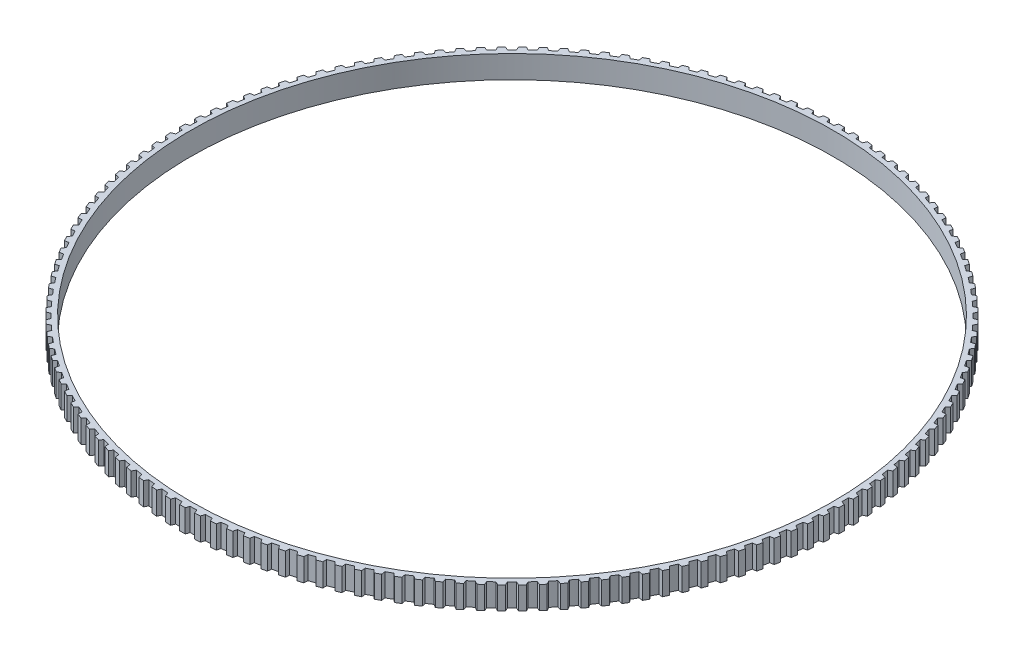
from build123d import *

# Parameters (mm, degrees)
SKETCH1_R      = 44.8691
EXTRUDE1_DEPTH = 3.175


with BuildPart() as part:
    # Sketch1 → Extrude1 (new body)
    with BuildSketch(Plane(origin=(0, 0, 0), x_dir=(1, 0, 0), z_dir=(0, 1, 0))):
        with BuildLine():
            Line((-0.381, 46.010522551), (-0.566606736, 45.500572234))
            ThreePointArc((-0.566606736, 45.500572234), (-1.021023922, 45.492643658), (-1.475339253, 45.4801769))
            Line((-1.475339253, 45.4801769), (-1.68363793, 45.981286517))
            ThreePointArc((-1.68363793, 45.981286517), (-2.064325061, 45.965768877), (-2.444870647, 45.947099516))
            Line((-2.444870647, 45.947099516), (-2.607411655, 45.42933547))
            ThreePointArc((-2.607411655, 45.42933547), (-3.061015558, 45.401027528), (-3.514314106, 45.368190543))
            Line((-3.514314106, 45.368190543), (-3.744885238, 45.859450291))
            ThreePointArc((-3.744885238, 45.859450291), (-4.124492845, 45.826868813), (-4.50381765, 45.791145137))
            Line((-4.50381765, 45.791145137), (-4.642965594, 45.266610071))
            ThreePointArc((-4.642965594, 45.266610071), (-5.094842717, 45.21797977), (-5.546211597, 45.164838688))
            Line((-5.546211597, 45.164838688), (-5.798590845, 45.645259235))
            ThreePointArc((-5.798590845, 45.645259235), (-6.17635445, 45.595679533), (-6.553694563, 45.542973486))
            Line((-6.553694563, 45.542973486), (-6.669169218, 45.012723743))
            ThreePointArc((-6.669169218, 45.012723743), (-7.118409541, 44.943869019), (-7.566939757, 44.870530859))
            Line((-7.566939757, 44.870530859), (-7.840618862, 45.339144702))
            ThreePointArc((-7.840618862, 45.339144702), (-8.215777699, 45.272666624), (-8.590373208, 45.203084348))
            Line((-8.590373208, 45.203084348), (-8.681942023, 44.66818778))
            ThreePointArc((-8.681942023, 44.66818778), (-9.127640835, 44.579247297), (-9.572429107, 44.485859751))
            Line((-9.572429107, 44.485859751), (-9.866856915, 44.941723165))
            ThreePointArc((-9.866856915, 44.941723165), (-10.238655465, 44.858480588), (-10.609751984, 44.772162213))
            Line((-10.609751984, 44.772162213), (-10.677230552, 44.233696031))
            ThreePointArc((-10.677230552, 44.233696031), (-11.118490275, 44.124848904), (-11.558640858, 44.011600043))
            Line((-11.558640858, 44.011600043), (-11.873224432, 44.453794978))
            ThreePointArc((-11.873224432, 44.453794978), (-12.240913942, 44.353955543), (-12.607764132, 44.251074902))
            Line((-12.607764132, 44.251074902), (-12.651016559, 43.710123505))
            ThreePointArc((-12.651016559, 43.710123505), (-13.086948555, 43.581588938), (-13.521575045, 43.448706829))
            Line((-13.521575045, 43.448706829), (-13.855680856, 43.876342765))
            ThreePointArc((-13.855680856, 43.876342765), (-14.218520847, 43.760107533), (-14.580385921, 43.640871815))
            Line((-14.580385921, 43.640871815), (-14.599325103, 43.098524608))
            ThreePointArc((-14.599325103, 43.098524608), (-15.029051463, 42.950561451), (-15.45727858, 42.798313702))
            Line((-15.45727858, 42.798313702), (-15.810233782, 43.210529437))
            ThreePointArc((-15.810233782, 43.210529437), (-16.167493543, 43.078132491), (-16.523644753, 42.942781821))
            Line((-16.523644753, 42.942781821), (-16.518232549, 42.400131017))
            ThreePointArc((-16.518232549, 42.400131017), (-16.940887861, 42.233037249), (-17.361853212, 42.061730467))
            Line((-17.361853212, 42.061730467), (-17.732947001, 42.457695852))
            ThreePointArc((-17.732947001, 42.457695852), (-18.083907059, 42.309403823), (-18.433627163, 42.158210778))
            Line((-18.433627163, 42.158210778), (-18.403874473, 41.616349206))
            ThreePointArc((-18.403874473, 41.616349206), (-18.818607566, 41.430461331), (-19.231463383, 41.240440504))
            Line((-19.231463383, 41.240440504), (-19.619948424, 41.619358119))
            ThreePointArc((-19.619948424, 41.619358119), (-19.963901993, 41.455469647), (-20.306486702, 41.28873871))
            Line((-20.306486702, 41.28873871), (-20.252453443, 40.748757605))
            ThreePointArc((-20.252453443, 40.748757605), (-20.658429099, 40.544449977), (-21.062343946, 40.336097782))
            Line((-21.062343946, 40.336097782), (-21.467437883, 40.697204537))
            ThreePointArc((-21.467437883, 40.697204537), (-21.803692285, 40.518049671), (-22.138451679, 40.336116616))
            Line((-22.138451679, 40.336116616), (-22.060246667, 39.79910343))
            ThreePointArc((-22.060246667, 39.79910343), (-22.456647306, 39.576787497), (-22.850807751, 39.350523528))
            Line((-22.850807751, 39.350523528), (-23.271694779, 39.693092202))
            ThreePointArc((-23.271694779, 39.693092202), (-23.599572842, 39.499031736), (-23.92583276, 39.302262952))
            Line((-23.92583276, 39.302262952), (-23.82361349, 38.769299157))
            ThreePointArc((-23.82361349, 38.769299157), (-24.209640813, 38.529422634), (-24.59325307, 38.285702556))
            Line((-24.59325307, 38.285702556), (-25.029085579, 38.609043261))
            ThreePointArc((-25.029085579, 38.609043261), (-25.347927, 38.400468008), (-25.665030398, 38.189259761))
            Line((-25.665030398, 38.189259761), (-25.539002726, 37.661418675))
            ThreePointArc((-25.539002726, 37.661418675), (-25.913879326, 37.404464641), (-26.286170851, 37.143779275))
            Line((-26.286170851, 37.143779275), (-26.736071131, 37.447240845))
            ThreePointArc((-26.736071131, 37.447240845), (-27.045233807, 37.224570847), (-27.352542081, 36.999348483))
            Line((-27.352542081, 36.999348483), (-27.202959809, 36.477693108))
            ThreePointArc((-27.202959809, 36.477693108), (-27.565930734, 36.204179035), (-27.926151782, 35.927053365))
            Line((-27.926151782, 35.927053365), (-28.389213794, 36.21002467))
            ThreePointArc((-28.389213794, 36.21002467), (-28.688075112, 35.973708354), (-28.984969384, 35.734925441))
            Line((-28.984969384, 35.734925441), (-28.812133751, 35.220506321))
            ThreePointArc((-28.812133751, 35.220506321), (-29.162468026, 34.93098303), (-29.50989316, 34.63797515))
            Line((-29.50989316, 34.63797515), (-29.985184358, 34.899886324))
            ThreePointArc((-29.985184358, 34.899886324), (-30.273142452, 34.650399601), (-30.559024816, 34.398537014))
            Line((-30.559024816, 34.398537014), (-30.363283891, 33.892390122))
            ThreePointArc((-30.363283891, 33.892390122), (-30.700275989, 33.587440674), (-31.03420554, 33.279140664))
            Line((-31.03420554, 33.279140664), (-31.520768752, 33.519464251))
            ThreePointArc((-31.520768752, 33.519464251), (-31.797243711, 33.257309554), (-32.071538438, 32.992874513))
            Line((-32.071538438, 32.992874513), (-31.853286417, 32.49601916))
            ThreePointArc((-31.853286417, 32.49601916), (-32.176257682, 32.176257682), (-32.49601916, 31.853286417))
            Line((-32.49601916, 31.853286417), (-32.992874513, 32.071538438))
            ThreePointArc((-32.992874513, 32.071538438), (-33.257309554, 31.797243711), (-33.519464251, 31.520768752))
            Line((-33.519464251, 31.520768752), (-33.279140664, 31.03420554))
            ThreePointArc((-33.279140664, 31.03420554), (-33.587440674, 30.700275989), (-33.892390122, 30.363283891))
            Line((-33.892390122, 30.363283891), (-34.398537014, 30.559024816))
            ThreePointArc((-34.398537014, 30.559024816), (-34.650399601, 30.273142452), (-34.899886324, 29.985184358))
            Line((-34.899886324, 29.985184358), (-34.63797515, 29.50989316))
            ThreePointArc((-34.63797515, 29.50989316), (-34.93098303, 29.162468026), (-35.220506321, 28.812133751))
            Line((-35.220506321, 28.812133751), (-35.734925441, 28.984969384))
            ThreePointArc((-35.734925441, 28.984969384), (-35.973708354, 28.688075112), (-36.21002467, 28.389213794))
            Line((-36.21002467, 28.389213794), (-35.927053365, 27.926151782))
            ThreePointArc((-35.927053365, 27.926151782), (-36.204179035, 27.565930734), (-36.477693108, 27.202959809))
            Line((-36.477693108, 27.202959809), (-36.999348483, 27.352542081))
            ThreePointArc((-36.999348483, 27.352542081), (-37.224570847, 27.045233807), (-37.447240845, 26.736071131))
            Line((-37.447240845, 26.736071131), (-37.143779275, 26.286170851))
            ThreePointArc((-37.143779275, 26.286170851), (-37.404464641, 25.913879326), (-37.661418675, 25.539002726))
            Line((-37.661418675, 25.539002726), (-38.189259761, 25.665030398))
            ThreePointArc((-38.189259761, 25.665030398), (-38.400468008, 25.347927), (-38.609043261, 25.029085579))
            Line((-38.609043261, 25.029085579), (-38.285702556, 24.59325307))
            ThreePointArc((-38.285702556, 24.59325307), (-38.529422634, 24.209640813), (-38.769299157, 23.82361349))
            Line((-38.769299157, 23.82361349), (-39.302262952, 23.92583276))
            ThreePointArc((-39.302262952, 23.92583276), (-39.499031736, 23.599572842), (-39.693092202, 23.271694779))
            Line((-39.693092202, 23.271694779), (-39.350523528, 22.850807751))
            ThreePointArc((-39.350523528, 22.850807751), (-39.576787497, 22.456647306), (-39.79910343, 22.060246667))
            Line((-39.79910343, 22.060246667), (-40.336116616, 22.138451679))
            ThreePointArc((-40.336116616, 22.138451679), (-40.518049671, 21.803692285), (-40.697204537, 21.467437883))
            Line((-40.697204537, 21.467437883), (-40.336097782, 21.062343946))
            ThreePointArc((-40.336097782, 21.062343946), (-40.544449977, 20.658429099), (-40.748757605, 20.252453443))
            Line((-40.748757605, 20.252453443), (-41.28873871, 20.306486702))
            ThreePointArc((-41.28873871, 20.306486702), (-41.455469647, 19.963901993), (-41.619358119, 19.619948424))
            Line((-41.619358119, 19.619948424), (-41.240440504, 19.231463383))
            ThreePointArc((-41.240440504, 19.231463383), (-41.430461331, 18.818607566), (-41.616349206, 18.403874473))
            Line((-41.616349206, 18.403874473), (-42.158210778, 18.433627163))
            ThreePointArc((-42.158210778, 18.433627163), (-42.309403823, 18.083907059), (-42.457695852, 17.732947001))
            Line((-42.457695852, 17.732947001), (-42.061730467, 17.361853212))
            ThreePointArc((-42.061730467, 17.361853212), (-42.233037249, 16.940887861), (-42.400131017, 16.518232549))
            Line((-42.400131017, 16.518232549), (-42.942781821, 16.523644753))
            ThreePointArc((-42.942781821, 16.523644753), (-43.078132491, 16.167493543), (-43.210529437, 15.810233782))
            Line((-43.210529437, 15.810233782), (-42.798313702, 15.45727858))
            ThreePointArc((-42.798313702, 15.45727858), (-42.950561451, 15.029051463), (-43.098524608, 14.599325103))
            Line((-43.098524608, 14.599325103), (-43.640871815, 14.580385921))
            ThreePointArc((-43.640871815, 14.580385921), (-43.760107533, 14.218520847), (-43.876342765, 13.855680856))
            Line((-43.876342765, 13.855680856), (-43.448706829, 13.521575045))
            ThreePointArc((-43.448706829, 13.521575045), (-43.581588938, 13.086948555), (-43.710123505, 12.651016559))
            Line((-43.710123505, 12.651016559), (-44.251074902, 12.607764132))
            ThreePointArc((-44.251074902, 12.607764132), (-44.353955543, 12.240913942), (-44.453794978, 11.873224432))
            Line((-44.453794978, 11.873224432), (-44.011600043, 11.558640858))
            ThreePointArc((-44.011600043, 11.558640858), (-44.124848904, 11.118490275), (-44.233696031, 10.677230552))
            Line((-44.233696031, 10.677230552), (-44.772162213, 10.609751984))
            ThreePointArc((-44.772162213, 10.609751984), (-44.858480588, 10.238655465), (-44.941723165, 9.866856915))
            Line((-44.941723165, 9.866856915), (-44.485859751, 9.572429107))
            ThreePointArc((-44.485859751, 9.572429107), (-44.579247297, 9.127640835), (-44.66818778, 8.681942023))
            Line((-44.66818778, 8.681942023), (-45.203084348, 8.590373208))
            ThreePointArc((-45.203084348, 8.590373208), (-45.272666624, 8.215777699), (-45.339144702, 7.840618862))
            Line((-45.339144702, 7.840618862), (-44.870530859, 7.566939757))
            ThreePointArc((-44.870530859, 7.566939757), (-44.943869019, 7.118409541), (-45.012723743, 6.669169218))
            Line((-45.012723743, 6.669169218), (-45.542973486, 6.553694563))
            ThreePointArc((-45.542973486, 6.553694563), (-45.595679533, 6.17635445), (-45.645259235, 5.798590845))
            Line((-45.645259235, 5.798590845), (-45.164838688, 5.546211597))
            ThreePointArc((-45.164838688, 5.546211597), (-45.21797977, 5.094842717), (-45.266610071, 4.642965594))
            Line((-45.266610071, 4.642965594), (-45.791145137, 4.50381765))
            ThreePointArc((-45.791145137, 4.50381765), (-45.826868813, 4.124492845), (-45.859450291, 3.744885238))
            Line((-45.859450291, 3.744885238), (-45.368190543, 3.514314106))
            ThreePointArc((-45.368190543, 3.514314106), (-45.401027528, 3.061015558), (-45.42933547, 2.607411655))
            Line((-45.42933547, 2.607411655), (-45.947099516, 2.444870647))
            ThreePointArc((-45.947099516, 2.444870647), (-45.965768877, 2.064325061), (-45.981286517, 1.68363793))
            Line((-45.981286517, 1.68363793), (-45.4801769, 1.475339253))
            ThreePointArc((-45.4801769, 1.475339253), (-45.492643658, 1.021023922), (-45.500572234, 0.566606736))
            Line((-45.500572234, 0.566606736), (-46.010522551, 0.381))
            ThreePointArc((-46.010522551, 0.381), (-46.0121, 0), (-46.010522551, -0.381))
            Line((-46.010522551, -0.381), (-45.500572234, -0.566606736))
            ThreePointArc((-45.500572234, -0.566606736), (-45.492643658, -1.021023922), (-45.4801769, -1.475339253))
            Line((-45.4801769, -1.475339253), (-45.981286517, -1.68363793))
            ThreePointArc((-45.981286517, -1.68363793), (-45.965768877, -2.064325061), (-45.947099516, -2.444870647))
            Line((-45.947099516, -2.444870647), (-45.42933547, -2.607411655))
            ThreePointArc((-45.42933547, -2.607411655), (-45.401027528, -3.061015558), (-45.368190543, -3.514314106))
            Line((-45.368190543, -3.514314106), (-45.859450291, -3.744885238))
            ThreePointArc((-45.859450291, -3.744885238), (-45.826868813, -4.124492845), (-45.791145137, -4.50381765))
            Line((-45.791145137, -4.50381765), (-45.266610071, -4.642965594))
            ThreePointArc((-45.266610071, -4.642965594), (-45.21797977, -5.094842717), (-45.164838688, -5.546211597))
            Line((-45.164838688, -5.546211597), (-45.645259235, -5.798590845))
            ThreePointArc((-45.645259235, -5.798590845), (-45.595679533, -6.17635445), (-45.542973486, -6.553694563))
            Line((-45.542973486, -6.553694563), (-45.012723743, -6.669169218))
            ThreePointArc((-45.012723743, -6.669169218), (-44.943869019, -7.118409541), (-44.870530859, -7.566939757))
            Line((-44.870530859, -7.566939757), (-45.339144702, -7.840618862))
            ThreePointArc((-45.339144702, -7.840618862), (-45.272666624, -8.215777699), (-45.203084348, -8.590373208))
            Line((-45.203084348, -8.590373208), (-44.66818778, -8.681942023))
            ThreePointArc((-44.66818778, -8.681942023), (-44.579247297, -9.127640835), (-44.485859751, -9.572429107))
            Line((-44.485859751, -9.572429107), (-44.941723165, -9.866856915))
            ThreePointArc((-44.941723165, -9.866856915), (-44.858480588, -10.238655465), (-44.772162213, -10.609751984))
            Line((-44.772162213, -10.609751984), (-44.233696031, -10.677230552))
            ThreePointArc((-44.233696031, -10.677230552), (-44.124848904, -11.118490275), (-44.011600043, -11.558640858))
            Line((-44.011600043, -11.558640858), (-44.453794978, -11.873224432))
            ThreePointArc((-44.453794978, -11.873224432), (-44.353955543, -12.240913942), (-44.251074902, -12.607764132))
            Line((-44.251074902, -12.607764132), (-43.710123505, -12.651016559))
            ThreePointArc((-43.710123505, -12.651016559), (-43.581588938, -13.086948555), (-43.448706829, -13.521575045))
            Line((-43.448706829, -13.521575045), (-43.876342765, -13.855680856))
            ThreePointArc((-43.876342765, -13.855680856), (-43.760107533, -14.218520847), (-43.640871815, -14.580385921))
            Line((-43.640871815, -14.580385921), (-43.098524608, -14.599325103))
            ThreePointArc((-43.098524608, -14.599325103), (-42.950561451, -15.029051463), (-42.798313702, -15.45727858))
            Line((-42.798313702, -15.45727858), (-43.210529437, -15.810233782))
            ThreePointArc((-43.210529437, -15.810233782), (-43.078132491, -16.167493543), (-42.942781821, -16.523644753))
            Line((-42.942781821, -16.523644753), (-42.400131017, -16.518232549))
            ThreePointArc((-42.400131017, -16.518232549), (-42.233037249, -16.940887861), (-42.061730467, -17.361853212))
            Line((-42.061730467, -17.361853212), (-42.457695852, -17.732947001))
            ThreePointArc((-42.457695852, -17.732947001), (-42.309403823, -18.083907059), (-42.158210778, -18.433627163))
            Line((-42.158210778, -18.433627163), (-41.616349206, -18.403874473))
            ThreePointArc((-41.616349206, -18.403874473), (-41.430461331, -18.818607566), (-41.240440504, -19.231463383))
            Line((-41.240440504, -19.231463383), (-41.619358119, -19.619948424))
            ThreePointArc((-41.619358119, -19.619948424), (-41.455469647, -19.963901993), (-41.28873871, -20.306486702))
            Line((-41.28873871, -20.306486702), (-40.748757605, -20.252453443))
            ThreePointArc((-40.748757605, -20.252453443), (-40.544449977, -20.658429099), (-40.336097782, -21.062343946))
            Line((-40.336097782, -21.062343946), (-40.697204537, -21.467437883))
            ThreePointArc((-40.697204537, -21.467437883), (-40.518049671, -21.803692285), (-40.336116616, -22.138451679))
            Line((-40.336116616, -22.138451679), (-39.79910343, -22.060246667))
            ThreePointArc((-39.79910343, -22.060246667), (-39.576787497, -22.456647306), (-39.350523528, -22.850807751))
            Line((-39.350523528, -22.850807751), (-39.693092202, -23.271694779))
            ThreePointArc((-39.693092202, -23.271694779), (-39.499031736, -23.599572842), (-39.302262952, -23.92583276))
            Line((-39.302262952, -23.92583276), (-38.769299157, -23.82361349))
            ThreePointArc((-38.769299157, -23.82361349), (-38.529422634, -24.209640813), (-38.285702556, -24.59325307))
            Line((-38.285702556, -24.59325307), (-38.609043261, -25.029085579))
            ThreePointArc((-38.609043261, -25.029085579), (-38.400468008, -25.347927), (-38.189259761, -25.665030398))
            Line((-38.189259761, -25.665030398), (-37.661418675, -25.539002726))
            ThreePointArc((-37.661418675, -25.539002726), (-37.404464641, -25.913879326), (-37.143779275, -26.286170851))
            Line((-37.143779275, -26.286170851), (-37.447240845, -26.736071131))
            ThreePointArc((-37.447240845, -26.736071131), (-37.224570847, -27.045233807), (-36.999348483, -27.352542081))
            Line((-36.999348483, -27.352542081), (-36.477693108, -27.202959809))
            ThreePointArc((-36.477693108, -27.202959809), (-36.204179035, -27.565930734), (-35.927053365, -27.926151782))
            Line((-35.927053365, -27.926151782), (-36.21002467, -28.389213794))
            ThreePointArc((-36.21002467, -28.389213794), (-35.973708354, -28.688075112), (-35.734925441, -28.984969384))
            Line((-35.734925441, -28.984969384), (-35.220506321, -28.812133751))
            ThreePointArc((-35.220506321, -28.812133751), (-34.93098303, -29.162468026), (-34.63797515, -29.50989316))
            Line((-34.63797515, -29.50989316), (-34.899886324, -29.985184358))
            ThreePointArc((-34.899886324, -29.985184358), (-34.650399601, -30.273142452), (-34.398537014, -30.559024816))
            Line((-34.398537014, -30.559024816), (-33.892390122, -30.363283891))
            ThreePointArc((-33.892390122, -30.363283891), (-33.587440674, -30.700275989), (-33.279140664, -31.03420554))
            Line((-33.279140664, -31.03420554), (-33.519464251, -31.520768752))
            ThreePointArc((-33.519464251, -31.520768752), (-33.257309554, -31.797243711), (-32.992874513, -32.071538438))
            Line((-32.992874513, -32.071538438), (-32.49601916, -31.853286417))
            ThreePointArc((-32.49601916, -31.853286417), (-32.176257682, -32.176257682), (-31.853286417, -32.49601916))
            Line((-31.853286417, -32.49601916), (-32.071538438, -32.992874513))
            ThreePointArc((-32.071538438, -32.992874513), (-31.797243711, -33.257309554), (-31.520768752, -33.519464251))
            Line((-31.520768752, -33.519464251), (-31.03420554, -33.279140664))
            ThreePointArc((-31.03420554, -33.279140664), (-30.700275989, -33.587440674), (-30.363283891, -33.892390122))
            Line((-30.363283891, -33.892390122), (-30.559024816, -34.398537014))
            ThreePointArc((-30.559024816, -34.398537014), (-30.273142452, -34.650399601), (-29.985184358, -34.899886324))
            Line((-29.985184358, -34.899886324), (-29.50989316, -34.63797515))
            ThreePointArc((-29.50989316, -34.63797515), (-29.162468026, -34.93098303), (-28.812133751, -35.220506321))
            Line((-28.812133751, -35.220506321), (-28.984969384, -35.734925441))
            ThreePointArc((-28.984969384, -35.734925441), (-28.688075112, -35.973708354), (-28.389213794, -36.21002467))
            Line((-28.389213794, -36.21002467), (-27.926151782, -35.927053365))
            ThreePointArc((-27.926151782, -35.927053365), (-27.565930734, -36.204179035), (-27.202959809, -36.477693108))
            Line((-27.202959809, -36.477693108), (-27.352542081, -36.999348483))
            ThreePointArc((-27.352542081, -36.999348483), (-27.045233807, -37.224570847), (-26.736071131, -37.447240845))
            Line((-26.736071131, -37.447240845), (-26.286170851, -37.143779275))
            ThreePointArc((-26.286170851, -37.143779275), (-25.913879326, -37.404464641), (-25.539002726, -37.661418675))
            Line((-25.539002726, -37.661418675), (-25.665030398, -38.189259761))
            ThreePointArc((-25.665030398, -38.189259761), (-25.347927, -38.400468008), (-25.029085579, -38.609043261))
            Line((-25.029085579, -38.609043261), (-24.59325307, -38.285702556))
            ThreePointArc((-24.59325307, -38.285702556), (-24.209640813, -38.529422634), (-23.82361349, -38.769299157))
            Line((-23.82361349, -38.769299157), (-23.92583276, -39.302262952))
            ThreePointArc((-23.92583276, -39.302262952), (-23.599572842, -39.499031736), (-23.271694779, -39.693092202))
            Line((-23.271694779, -39.693092202), (-22.850807751, -39.350523528))
            ThreePointArc((-22.850807751, -39.350523528), (-22.456647306, -39.576787497), (-22.060246667, -39.79910343))
            Line((-22.060246667, -39.79910343), (-22.138451679, -40.336116616))
            ThreePointArc((-22.138451679, -40.336116616), (-21.803692285, -40.518049671), (-21.467437883, -40.697204537))
            Line((-21.467437883, -40.697204537), (-21.062343946, -40.336097782))
            ThreePointArc((-21.062343946, -40.336097782), (-20.658429099, -40.544449977), (-20.252453443, -40.748757605))
            Line((-20.252453443, -40.748757605), (-20.306486702, -41.28873871))
            ThreePointArc((-20.306486702, -41.28873871), (-19.963901993, -41.455469647), (-19.619948424, -41.619358119))
            Line((-19.619948424, -41.619358119), (-19.231463383, -41.240440504))
            ThreePointArc((-19.231463383, -41.240440504), (-18.818607566, -41.430461331), (-18.403874473, -41.616349206))
            Line((-18.403874473, -41.616349206), (-18.433627163, -42.158210778))
            ThreePointArc((-18.433627163, -42.158210778), (-18.083907059, -42.309403823), (-17.732947001, -42.457695852))
            Line((-17.732947001, -42.457695852), (-17.361853212, -42.061730467))
            ThreePointArc((-17.361853212, -42.061730467), (-16.940887861, -42.233037249), (-16.518232549, -42.400131017))
            Line((-16.518232549, -42.400131017), (-16.523644753, -42.942781821))
            ThreePointArc((-16.523644753, -42.942781821), (-16.167493543, -43.078132491), (-15.810233782, -43.210529437))
            Line((-15.810233782, -43.210529437), (-15.45727858, -42.798313702))
            ThreePointArc((-15.45727858, -42.798313702), (-15.029051463, -42.950561451), (-14.599325103, -43.098524608))
            Line((-14.599325103, -43.098524608), (-14.580385921, -43.640871815))
            ThreePointArc((-14.580385921, -43.640871815), (-14.218520847, -43.760107533), (-13.855680856, -43.876342765))
            Line((-13.855680856, -43.876342765), (-13.521575045, -43.448706829))
            ThreePointArc((-13.521575045, -43.448706829), (-13.086948555, -43.581588938), (-12.651016559, -43.710123505))
            Line((-12.651016559, -43.710123505), (-12.607764132, -44.251074902))
            ThreePointArc((-12.607764132, -44.251074902), (-12.240913942, -44.353955543), (-11.873224432, -44.453794978))
            Line((-11.873224432, -44.453794978), (-11.558640858, -44.011600043))
            ThreePointArc((-11.558640858, -44.011600043), (-11.118490275, -44.124848904), (-10.677230552, -44.233696031))
            Line((-10.677230552, -44.233696031), (-10.609751984, -44.772162213))
            ThreePointArc((-10.609751984, -44.772162213), (-10.238655465, -44.858480588), (-9.866856915, -44.941723165))
            Line((-9.866856915, -44.941723165), (-9.572429107, -44.485859751))
            ThreePointArc((-9.572429107, -44.485859751), (-9.127640835, -44.579247297), (-8.681942023, -44.66818778))
            Line((-8.681942023, -44.66818778), (-8.590373208, -45.203084348))
            ThreePointArc((-8.590373208, -45.203084348), (-8.215777699, -45.272666624), (-7.840618862, -45.339144702))
            Line((-7.840618862, -45.339144702), (-7.566939757, -44.870530859))
            ThreePointArc((-7.566939757, -44.870530859), (-7.118409541, -44.943869019), (-6.669169218, -45.012723743))
            Line((-6.669169218, -45.012723743), (-6.553694563, -45.542973486))
            ThreePointArc((-6.553694563, -45.542973486), (-6.17635445, -45.595679533), (-5.798590845, -45.645259235))
            Line((-5.798590845, -45.645259235), (-5.546211597, -45.164838688))
            ThreePointArc((-5.546211597, -45.164838688), (-5.094842717, -45.21797977), (-4.642965594, -45.266610071))
            Line((-4.642965594, -45.266610071), (-4.50381765, -45.791145137))
            ThreePointArc((-4.50381765, -45.791145137), (-4.124492845, -45.826868813), (-3.744885238, -45.859450291))
            Line((-3.744885238, -45.859450291), (-3.514314106, -45.368190543))
            ThreePointArc((-3.514314106, -45.368190543), (-3.061015558, -45.401027528), (-2.607411655, -45.42933547))
            Line((-2.607411655, -45.42933547), (-2.444870647, -45.947099516))
            ThreePointArc((-2.444870647, -45.947099516), (-2.064325061, -45.965768877), (-1.68363793, -45.981286517))
            Line((-1.68363793, -45.981286517), (-1.475339253, -45.4801769))
            ThreePointArc((-1.475339253, -45.4801769), (-1.021023922, -45.492643658), (-0.566606736, -45.500572234))
            Line((-0.566606736, -45.500572234), (-0.381, -46.010522551))
            ThreePointArc((-0.381, -46.010522551), (0, -46.0121), (0.381, -46.010522551))
            Line((0.381, -46.010522551), (0.566606736, -45.500572234))
            ThreePointArc((0.566606736, -45.500572234), (1.021023922, -45.492643658), (1.475339253, -45.4801769))
            Line((1.475339253, -45.4801769), (1.68363793, -45.981286517))
            ThreePointArc((1.68363793, -45.981286517), (2.064325061, -45.965768877), (2.444870647, -45.947099516))
            Line((2.444870647, -45.947099516), (2.607411655, -45.42933547))
            ThreePointArc((2.607411655, -45.42933547), (3.061015558, -45.401027528), (3.514314106, -45.368190543))
            Line((3.514314106, -45.368190543), (3.744885238, -45.859450291))
            ThreePointArc((3.744885238, -45.859450291), (4.124492845, -45.826868813), (4.50381765, -45.791145137))
            Line((4.50381765, -45.791145137), (4.642965594, -45.266610071))
            ThreePointArc((4.642965594, -45.266610071), (5.094842717, -45.21797977), (5.546211597, -45.164838688))
            Line((5.546211597, -45.164838688), (5.798590845, -45.645259235))
            ThreePointArc((5.798590845, -45.645259235), (6.17635445, -45.595679533), (6.553694563, -45.542973486))
            Line((6.553694563, -45.542973486), (6.669169218, -45.012723743))
            ThreePointArc((6.669169218, -45.012723743), (7.118409541, -44.943869019), (7.566939757, -44.870530859))
            Line((7.566939757, -44.870530859), (7.840618862, -45.339144702))
            ThreePointArc((7.840618862, -45.339144702), (8.215777699, -45.272666624), (8.590373208, -45.203084348))
            Line((8.590373208, -45.203084348), (8.681942023, -44.66818778))
            ThreePointArc((8.681942023, -44.66818778), (9.127640835, -44.579247297), (9.572429107, -44.485859751))
            Line((9.572429107, -44.485859751), (9.866856915, -44.941723165))
            ThreePointArc((9.866856915, -44.941723165), (10.238655465, -44.858480588), (10.609751984, -44.772162213))
            Line((10.609751984, -44.772162213), (10.677230552, -44.233696031))
            ThreePointArc((10.677230552, -44.233696031), (11.118490275, -44.124848904), (11.558640858, -44.011600043))
            Line((11.558640858, -44.011600043), (11.873224432, -44.453794978))
            ThreePointArc((11.873224432, -44.453794978), (12.240913942, -44.353955543), (12.607764132, -44.251074902))
            Line((12.607764132, -44.251074902), (12.651016559, -43.710123505))
            ThreePointArc((12.651016559, -43.710123505), (13.086948555, -43.581588938), (13.521575045, -43.448706829))
            Line((13.521575045, -43.448706829), (13.855680856, -43.876342765))
            ThreePointArc((13.855680856, -43.876342765), (14.218520847, -43.760107533), (14.580385921, -43.640871815))
            Line((14.580385921, -43.640871815), (14.599325103, -43.098524608))
            ThreePointArc((14.599325103, -43.098524608), (15.029051463, -42.950561451), (15.45727858, -42.798313702))
            Line((15.45727858, -42.798313702), (15.810233782, -43.210529437))
            ThreePointArc((15.810233782, -43.210529437), (16.167493543, -43.078132491), (16.523644753, -42.942781821))
            Line((16.523644753, -42.942781821), (16.518232549, -42.400131017))
            ThreePointArc((16.518232549, -42.400131017), (16.940887861, -42.233037249), (17.361853212, -42.061730467))
            Line((17.361853212, -42.061730467), (17.732947001, -42.457695852))
            ThreePointArc((17.732947001, -42.457695852), (18.083907059, -42.309403823), (18.433627163, -42.158210778))
            Line((18.433627163, -42.158210778), (18.403874473, -41.616349206))
            ThreePointArc((18.403874473, -41.616349206), (18.818607566, -41.430461331), (19.231463383, -41.240440504))
            Line((19.231463383, -41.240440504), (19.619948424, -41.619358119))
            ThreePointArc((19.619948424, -41.619358119), (19.963901993, -41.455469647), (20.306486702, -41.28873871))
            Line((20.306486702, -41.28873871), (20.252453443, -40.748757605))
            ThreePointArc((20.252453443, -40.748757605), (20.658429099, -40.544449977), (21.062343946, -40.336097782))
            Line((21.062343946, -40.336097782), (21.467437883, -40.697204537))
            ThreePointArc((21.467437883, -40.697204537), (21.803692285, -40.518049671), (22.138451679, -40.336116616))
            Line((22.138451679, -40.336116616), (22.060246667, -39.79910343))
            ThreePointArc((22.060246667, -39.79910343), (22.456647306, -39.576787497), (22.850807751, -39.350523528))
            Line((22.850807751, -39.350523528), (23.271694779, -39.693092202))
            ThreePointArc((23.271694779, -39.693092202), (23.599572842, -39.499031736), (23.92583276, -39.302262952))
            Line((23.92583276, -39.302262952), (23.82361349, -38.769299157))
            ThreePointArc((23.82361349, -38.769299157), (24.209640813, -38.529422634), (24.59325307, -38.285702556))
            Line((24.59325307, -38.285702556), (25.029085579, -38.609043261))
            ThreePointArc((25.029085579, -38.609043261), (25.347927, -38.400468008), (25.665030398, -38.189259761))
            Line((25.665030398, -38.189259761), (25.539002726, -37.661418675))
            ThreePointArc((25.539002726, -37.661418675), (25.913879326, -37.404464641), (26.286170851, -37.143779275))
            Line((26.286170851, -37.143779275), (26.736071131, -37.447240845))
            ThreePointArc((26.736071131, -37.447240845), (27.045233807, -37.224570847), (27.352542081, -36.999348483))
            Line((27.352542081, -36.999348483), (27.202959809, -36.477693108))
            ThreePointArc((27.202959809, -36.477693108), (27.565930734, -36.204179035), (27.926151782, -35.927053365))
            Line((27.926151782, -35.927053365), (28.389213794, -36.21002467))
            ThreePointArc((28.389213794, -36.21002467), (28.688075112, -35.973708354), (28.984969384, -35.734925441))
            Line((28.984969384, -35.734925441), (28.812133751, -35.220506321))
            ThreePointArc((28.812133751, -35.220506321), (29.162468026, -34.93098303), (29.50989316, -34.63797515))
            Line((29.50989316, -34.63797515), (29.985184358, -34.899886324))
            ThreePointArc((29.985184358, -34.899886324), (30.273142452, -34.650399601), (30.559024816, -34.398537014))
            Line((30.559024816, -34.398537014), (30.363283891, -33.892390122))
            ThreePointArc((30.363283891, -33.892390122), (30.700275989, -33.587440674), (31.03420554, -33.279140664))
            Line((31.03420554, -33.279140664), (31.520768752, -33.519464251))
            ThreePointArc((31.520768752, -33.519464251), (31.797243711, -33.257309554), (32.071538438, -32.992874513))
            Line((32.071538438, -32.992874513), (31.853286417, -32.49601916))
            ThreePointArc((31.853286417, -32.49601916), (32.176257682, -32.176257682), (32.49601916, -31.853286417))
            Line((32.49601916, -31.853286417), (32.992874513, -32.071538438))
            ThreePointArc((32.992874513, -32.071538438), (33.257309554, -31.797243711), (33.519464251, -31.520768752))
            Line((33.519464251, -31.520768752), (33.279140664, -31.03420554))
            ThreePointArc((33.279140664, -31.03420554), (33.587440674, -30.700275989), (33.892390122, -30.363283891))
            Line((33.892390122, -30.363283891), (34.398537014, -30.559024816))
            ThreePointArc((34.398537014, -30.559024816), (34.650399601, -30.273142452), (34.899886324, -29.985184358))
            Line((34.899886324, -29.985184358), (34.63797515, -29.50989316))
            ThreePointArc((34.63797515, -29.50989316), (34.93098303, -29.162468026), (35.220506321, -28.812133751))
            Line((35.220506321, -28.812133751), (35.734925441, -28.984969384))
            ThreePointArc((35.734925441, -28.984969384), (35.973708354, -28.688075112), (36.21002467, -28.389213794))
            Line((36.21002467, -28.389213794), (35.927053365, -27.926151782))
            ThreePointArc((35.927053365, -27.926151782), (36.204179035, -27.565930734), (36.477693108, -27.202959809))
            Line((36.477693108, -27.202959809), (36.999348483, -27.352542081))
            ThreePointArc((36.999348483, -27.352542081), (37.224570847, -27.045233807), (37.447240845, -26.736071131))
            Line((37.447240845, -26.736071131), (37.143779275, -26.286170851))
            ThreePointArc((37.143779275, -26.286170851), (37.404464641, -25.913879326), (37.661418675, -25.539002726))
            Line((37.661418675, -25.539002726), (38.189259761, -25.665030398))
            ThreePointArc((38.189259761, -25.665030398), (38.400468008, -25.347927), (38.609043261, -25.029085579))
            Line((38.609043261, -25.029085579), (38.285702556, -24.59325307))
            ThreePointArc((38.285702556, -24.59325307), (38.529422634, -24.209640813), (38.769299157, -23.82361349))
            Line((38.769299157, -23.82361349), (39.302262952, -23.92583276))
            ThreePointArc((39.302262952, -23.92583276), (39.499031736, -23.599572842), (39.693092202, -23.271694779))
            Line((39.693092202, -23.271694779), (39.350523528, -22.850807751))
            ThreePointArc((39.350523528, -22.850807751), (39.576787497, -22.456647306), (39.79910343, -22.060246667))
            Line((39.79910343, -22.060246667), (40.336116616, -22.138451679))
            ThreePointArc((40.336116616, -22.138451679), (40.518049671, -21.803692285), (40.697204537, -21.467437883))
            Line((40.697204537, -21.467437883), (40.336097782, -21.062343946))
            ThreePointArc((40.336097782, -21.062343946), (40.544449977, -20.658429099), (40.748757605, -20.252453443))
            Line((40.748757605, -20.252453443), (41.28873871, -20.306486702))
            ThreePointArc((41.28873871, -20.306486702), (41.455469647, -19.963901993), (41.619358119, -19.619948424))
            Line((41.619358119, -19.619948424), (41.240440504, -19.231463383))
            ThreePointArc((41.240440504, -19.231463383), (41.430461331, -18.818607566), (41.616349206, -18.403874473))
            Line((41.616349206, -18.403874473), (42.158210778, -18.433627163))
            ThreePointArc((42.158210778, -18.433627163), (42.309403823, -18.083907059), (42.457695852, -17.732947001))
            Line((42.457695852, -17.732947001), (42.061730467, -17.361853212))
            ThreePointArc((42.061730467, -17.361853212), (42.233037249, -16.940887861), (42.400131017, -16.518232549))
            Line((42.400131017, -16.518232549), (42.942781821, -16.523644753))
            ThreePointArc((42.942781821, -16.523644753), (43.078132491, -16.167493543), (43.210529437, -15.810233782))
            Line((43.210529437, -15.810233782), (42.798313702, -15.45727858))
            ThreePointArc((42.798313702, -15.45727858), (42.950561451, -15.029051463), (43.098524608, -14.599325103))
            Line((43.098524608, -14.599325103), (43.640871815, -14.580385921))
            ThreePointArc((43.640871815, -14.580385921), (43.760107533, -14.218520847), (43.876342765, -13.855680856))
            Line((43.876342765, -13.855680856), (43.448706829, -13.521575045))
            ThreePointArc((43.448706829, -13.521575045), (43.581588938, -13.086948555), (43.710123505, -12.651016559))
            Line((43.710123505, -12.651016559), (44.251074902, -12.607764132))
            ThreePointArc((44.251074902, -12.607764132), (44.353955543, -12.240913942), (44.453794978, -11.873224432))
            Line((44.453794978, -11.873224432), (44.011600043, -11.558640858))
            ThreePointArc((44.011600043, -11.558640858), (44.124848904, -11.118490275), (44.233696031, -10.677230552))
            Line((44.233696031, -10.677230552), (44.772162213, -10.609751984))
            ThreePointArc((44.772162213, -10.609751984), (44.858480588, -10.238655465), (44.941723165, -9.866856915))
            Line((44.941723165, -9.866856915), (44.485859751, -9.572429107))
            ThreePointArc((44.485859751, -9.572429107), (44.579247297, -9.127640835), (44.66818778, -8.681942023))
            Line((44.66818778, -8.681942023), (45.203084348, -8.590373208))
            ThreePointArc((45.203084348, -8.590373208), (45.272666624, -8.215777699), (45.339144702, -7.840618862))
            Line((45.339144702, -7.840618862), (44.870530859, -7.566939757))
            ThreePointArc((44.870530859, -7.566939757), (44.943869019, -7.118409541), (45.012723743, -6.669169218))
            Line((45.012723743, -6.669169218), (45.542973486, -6.553694563))
            ThreePointArc((45.542973486, -6.553694563), (45.595679533, -6.17635445), (45.645259235, -5.798590845))
            Line((45.645259235, -5.798590845), (45.164838688, -5.546211597))
            ThreePointArc((45.164838688, -5.546211597), (45.21797977, -5.094842717), (45.266610071, -4.642965594))
            Line((45.266610071, -4.642965594), (45.791145137, -4.50381765))
            ThreePointArc((45.791145137, -4.50381765), (45.826868813, -4.124492845), (45.859450291, -3.744885238))
            Line((45.859450291, -3.744885238), (45.368190543, -3.514314106))
            ThreePointArc((45.368190543, -3.514314106), (45.401027528, -3.061015558), (45.42933547, -2.607411655))
            Line((45.42933547, -2.607411655), (45.947099516, -2.444870647))
            ThreePointArc((45.947099516, -2.444870647), (45.965768877, -2.064325061), (45.981286517, -1.68363793))
            Line((45.981286517, -1.68363793), (45.4801769, -1.475339253))
            ThreePointArc((45.4801769, -1.475339253), (45.492643658, -1.021023922), (45.500572234, -0.566606736))
            Line((45.500572234, -0.566606736), (46.010522551, -0.381))
            ThreePointArc((46.010522551, -0.381), (46.0121, 0), (46.010522551, 0.381))
            Line((46.010522551, 0.381), (45.500572234, 0.566606736))
            ThreePointArc((45.500572234, 0.566606736), (45.492643658, 1.021023922), (45.4801769, 1.475339253))
            Line((45.4801769, 1.475339253), (45.981286517, 1.68363793))
            ThreePointArc((45.981286517, 1.68363793), (45.965768877, 2.064325061), (45.947099516, 2.444870647))
            Line((45.947099516, 2.444870647), (45.42933547, 2.607411655))
            ThreePointArc((45.42933547, 2.607411655), (45.401027528, 3.061015558), (45.368190543, 3.514314106))
            Line((45.368190543, 3.514314106), (45.859450291, 3.744885238))
            ThreePointArc((45.859450291, 3.744885238), (45.826868813, 4.124492845), (45.791145137, 4.50381765))
            Line((45.791145137, 4.50381765), (45.266610071, 4.642965594))
            ThreePointArc((45.266610071, 4.642965594), (45.21797977, 5.094842717), (45.164838688, 5.546211597))
            Line((45.164838688, 5.546211597), (45.645259235, 5.798590845))
            ThreePointArc((45.645259235, 5.798590845), (45.595679533, 6.17635445), (45.542973486, 6.553694563))
            Line((45.542973486, 6.553694563), (45.012723743, 6.669169218))
            ThreePointArc((45.012723743, 6.669169218), (44.943869019, 7.118409541), (44.870530859, 7.566939757))
            Line((44.870530859, 7.566939757), (45.339144702, 7.840618862))
            ThreePointArc((45.339144702, 7.840618862), (45.272666624, 8.215777699), (45.203084348, 8.590373208))
            Line((45.203084348, 8.590373208), (44.66818778, 8.681942023))
            ThreePointArc((44.66818778, 8.681942023), (44.579247297, 9.127640835), (44.485859751, 9.572429107))
            Line((44.485859751, 9.572429107), (44.941723165, 9.866856915))
            ThreePointArc((44.941723165, 9.866856915), (44.858480588, 10.238655465), (44.772162213, 10.609751984))
            Line((44.772162213, 10.609751984), (44.233696031, 10.677230552))
            ThreePointArc((44.233696031, 10.677230552), (44.124848904, 11.118490275), (44.011600043, 11.558640858))
            Line((44.011600043, 11.558640858), (44.453794978, 11.873224432))
            ThreePointArc((44.453794978, 11.873224432), (44.353955543, 12.240913942), (44.251074902, 12.607764132))
            Line((44.251074902, 12.607764132), (43.710123505, 12.651016559))
            ThreePointArc((43.710123505, 12.651016559), (43.581588938, 13.086948555), (43.448706829, 13.521575045))
            Line((43.448706829, 13.521575045), (43.876342765, 13.855680856))
            ThreePointArc((43.876342765, 13.855680856), (43.760107533, 14.218520847), (43.640871815, 14.580385921))
            Line((43.640871815, 14.580385921), (43.098524608, 14.599325103))
            ThreePointArc((43.098524608, 14.599325103), (42.950561451, 15.029051463), (42.798313702, 15.45727858))
            Line((42.798313702, 15.45727858), (43.210529437, 15.810233782))
            ThreePointArc((43.210529437, 15.810233782), (43.078132491, 16.167493543), (42.942781821, 16.523644753))
            Line((42.942781821, 16.523644753), (42.400131017, 16.518232549))
            ThreePointArc((42.400131017, 16.518232549), (42.233037249, 16.940887861), (42.061730467, 17.361853212))
            Line((42.061730467, 17.361853212), (42.457695852, 17.732947001))
            ThreePointArc((42.457695852, 17.732947001), (42.309403823, 18.083907059), (42.158210778, 18.433627163))
            Line((42.158210778, 18.433627163), (41.616349206, 18.403874473))
            ThreePointArc((41.616349206, 18.403874473), (41.430461331, 18.818607566), (41.240440504, 19.231463383))
            Line((41.240440504, 19.231463383), (41.619358119, 19.619948424))
            ThreePointArc((41.619358119, 19.619948424), (41.455469647, 19.963901993), (41.28873871, 20.306486702))
            Line((41.28873871, 20.306486702), (40.748757605, 20.252453443))
            ThreePointArc((40.748757605, 20.252453443), (40.544449977, 20.658429099), (40.336097782, 21.062343946))
            Line((40.336097782, 21.062343946), (40.697204537, 21.467437883))
            ThreePointArc((40.697204537, 21.467437883), (40.518049671, 21.803692285), (40.336116616, 22.138451679))
            Line((40.336116616, 22.138451679), (39.79910343, 22.060246667))
            ThreePointArc((39.79910343, 22.060246667), (39.576787497, 22.456647306), (39.350523528, 22.850807751))
            Line((39.350523528, 22.850807751), (39.693092202, 23.271694779))
            ThreePointArc((39.693092202, 23.271694779), (39.499031736, 23.599572842), (39.302262952, 23.92583276))
            Line((39.302262952, 23.92583276), (38.769299157, 23.82361349))
            ThreePointArc((38.769299157, 23.82361349), (38.529422634, 24.209640813), (38.285702556, 24.59325307))
            Line((38.285702556, 24.59325307), (38.609043261, 25.029085579))
            ThreePointArc((38.609043261, 25.029085579), (38.400468008, 25.347927), (38.189259761, 25.665030398))
            Line((38.189259761, 25.665030398), (37.661418675, 25.539002726))
            ThreePointArc((37.661418675, 25.539002726), (37.404464641, 25.913879326), (37.143779275, 26.286170851))
            Line((37.143779275, 26.286170851), (37.447240845, 26.736071131))
            ThreePointArc((37.447240845, 26.736071131), (37.224570847, 27.045233807), (36.999348483, 27.352542081))
            Line((36.999348483, 27.352542081), (36.477693108, 27.202959809))
            ThreePointArc((36.477693108, 27.202959809), (36.204179035, 27.565930734), (35.927053365, 27.926151782))
            Line((35.927053365, 27.926151782), (36.21002467, 28.389213794))
            ThreePointArc((36.21002467, 28.389213794), (35.973708354, 28.688075112), (35.734925441, 28.984969384))
            Line((35.734925441, 28.984969384), (35.220506321, 28.812133751))
            ThreePointArc((35.220506321, 28.812133751), (34.93098303, 29.162468026), (34.63797515, 29.50989316))
            Line((34.63797515, 29.50989316), (34.899886324, 29.985184358))
            ThreePointArc((34.899886324, 29.985184358), (34.650399601, 30.273142452), (34.398537014, 30.559024816))
            Line((34.398537014, 30.559024816), (33.892390122, 30.363283891))
            ThreePointArc((33.892390122, 30.363283891), (33.587440674, 30.700275989), (33.279140664, 31.03420554))
            Line((33.279140664, 31.03420554), (33.519464251, 31.520768752))
            ThreePointArc((33.519464251, 31.520768752), (33.257309554, 31.797243711), (32.992874513, 32.071538438))
            Line((32.992874513, 32.071538438), (32.49601916, 31.853286417))
            ThreePointArc((32.49601916, 31.853286417), (32.176257682, 32.176257682), (31.853286417, 32.49601916))
            Line((31.853286417, 32.49601916), (32.071538438, 32.992874513))
            ThreePointArc((32.071538438, 32.992874513), (31.797243711, 33.257309554), (31.520768752, 33.519464251))
            Line((31.520768752, 33.519464251), (31.03420554, 33.279140664))
            ThreePointArc((31.03420554, 33.279140664), (30.700275989, 33.587440674), (30.363283891, 33.892390122))
            Line((30.363283891, 33.892390122), (30.559024816, 34.398537014))
            ThreePointArc((30.559024816, 34.398537014), (30.273142452, 34.650399601), (29.985184358, 34.899886324))
            Line((29.985184358, 34.899886324), (29.50989316, 34.63797515))
            ThreePointArc((29.50989316, 34.63797515), (29.162468026, 34.93098303), (28.812133751, 35.220506321))
            Line((28.812133751, 35.220506321), (28.984969384, 35.734925441))
            ThreePointArc((28.984969384, 35.734925441), (28.688075112, 35.973708354), (28.389213794, 36.21002467))
            Line((28.389213794, 36.21002467), (27.926151782, 35.927053365))
            ThreePointArc((27.926151782, 35.927053365), (27.565930734, 36.204179035), (27.202959809, 36.477693108))
            Line((27.202959809, 36.477693108), (27.352542081, 36.999348483))
            ThreePointArc((27.352542081, 36.999348483), (27.045233807, 37.224570847), (26.736071131, 37.447240845))
            Line((26.736071131, 37.447240845), (26.286170851, 37.143779275))
            ThreePointArc((26.286170851, 37.143779275), (25.913879326, 37.404464641), (25.539002726, 37.661418675))
            Line((25.539002726, 37.661418675), (25.665030398, 38.189259761))
            ThreePointArc((25.665030398, 38.189259761), (25.347927, 38.400468008), (25.029085579, 38.609043261))
            Line((25.029085579, 38.609043261), (24.59325307, 38.285702556))
            ThreePointArc((24.59325307, 38.285702556), (24.209640813, 38.529422634), (23.82361349, 38.769299157))
            Line((23.82361349, 38.769299157), (23.92583276, 39.302262952))
            ThreePointArc((23.92583276, 39.302262952), (23.599572842, 39.499031736), (23.271694779, 39.693092202))
            Line((23.271694779, 39.693092202), (22.850807751, 39.350523528))
            ThreePointArc((22.850807751, 39.350523528), (22.456647306, 39.576787497), (22.060246667, 39.79910343))
            Line((22.060246667, 39.79910343), (22.138451679, 40.336116616))
            ThreePointArc((22.138451679, 40.336116616), (21.803692285, 40.518049671), (21.467437883, 40.697204537))
            Line((21.467437883, 40.697204537), (21.062343946, 40.336097782))
            ThreePointArc((21.062343946, 40.336097782), (20.658429099, 40.544449977), (20.252453443, 40.748757605))
            Line((20.252453443, 40.748757605), (20.306486702, 41.28873871))
            ThreePointArc((20.306486702, 41.28873871), (19.963901993, 41.455469647), (19.619948424, 41.619358119))
            Line((19.619948424, 41.619358119), (19.231463383, 41.240440504))
            ThreePointArc((19.231463383, 41.240440504), (18.818607566, 41.430461331), (18.403874473, 41.616349206))
            Line((18.403874473, 41.616349206), (18.433627163, 42.158210778))
            ThreePointArc((18.433627163, 42.158210778), (18.083907059, 42.309403823), (17.732947001, 42.457695852))
            Line((17.732947001, 42.457695852), (17.361853212, 42.061730467))
            ThreePointArc((17.361853212, 42.061730467), (16.940887861, 42.233037249), (16.518232549, 42.400131017))
            Line((16.518232549, 42.400131017), (16.523644753, 42.942781821))
            ThreePointArc((16.523644753, 42.942781821), (16.167493543, 43.078132491), (15.810233782, 43.210529437))
            Line((15.810233782, 43.210529437), (15.45727858, 42.798313702))
            ThreePointArc((15.45727858, 42.798313702), (15.029051463, 42.950561451), (14.599325103, 43.098524608))
            Line((14.599325103, 43.098524608), (14.580385921, 43.640871815))
            ThreePointArc((14.580385921, 43.640871815), (14.218520847, 43.760107533), (13.855680856, 43.876342765))
            Line((13.855680856, 43.876342765), (13.521575045, 43.448706829))
            ThreePointArc((13.521575045, 43.448706829), (13.086948555, 43.581588938), (12.651016559, 43.710123505))
            Line((12.651016559, 43.710123505), (12.607764132, 44.251074902))
            ThreePointArc((12.607764132, 44.251074902), (12.240913942, 44.353955543), (11.873224432, 44.453794978))
            Line((11.873224432, 44.453794978), (11.558640858, 44.011600043))
            ThreePointArc((11.558640858, 44.011600043), (11.118490275, 44.124848904), (10.677230552, 44.233696031))
            Line((10.677230552, 44.233696031), (10.609751984, 44.772162213))
            ThreePointArc((10.609751984, 44.772162213), (10.238655465, 44.858480588), (9.866856915, 44.941723165))
            Line((9.866856915, 44.941723165), (9.572429107, 44.485859751))
            ThreePointArc((9.572429107, 44.485859751), (9.127640835, 44.579247297), (8.681942023, 44.66818778))
            Line((8.681942023, 44.66818778), (8.590373208, 45.203084348))
            ThreePointArc((8.590373208, 45.203084348), (8.215777699, 45.272666624), (7.840618862, 45.339144702))
            Line((7.840618862, 45.339144702), (7.566939757, 44.870530859))
            ThreePointArc((7.566939757, 44.870530859), (7.118409541, 44.943869019), (6.669169218, 45.012723743))
            Line((6.669169218, 45.012723743), (6.553694563, 45.542973486))
            ThreePointArc((6.553694563, 45.542973486), (6.17635445, 45.595679533), (5.798590845, 45.645259235))
            Line((5.798590845, 45.645259235), (5.546211597, 45.164838688))
            ThreePointArc((5.546211597, 45.164838688), (5.094842717, 45.21797977), (4.642965594, 45.266610071))
            Line((4.642965594, 45.266610071), (4.50381765, 45.791145137))
            ThreePointArc((4.50381765, 45.791145137), (4.124492845, 45.826868813), (3.744885238, 45.859450291))
            Line((3.744885238, 45.859450291), (3.514314106, 45.368190543))
            ThreePointArc((3.514314106, 45.368190543), (3.061015558, 45.401027528), (2.607411655, 45.42933547))
            Line((2.607411655, 45.42933547), (2.444870647, 45.947099516))
            ThreePointArc((2.444870647, 45.947099516), (2.064325061, 45.965768877), (1.68363793, 45.981286517))
            Line((1.68363793, 45.981286517), (1.475339253, 45.4801769))
            ThreePointArc((1.475339253, 45.4801769), (1.021023922, 45.492643658), (0.566606736, 45.500572234))
            Line((0.566606736, 45.500572234), (0.381, 46.010522551))
            ThreePointArc((0.381, 46.010522551), (0, 46.0121), (-0.381, 46.010522551))
        make_face()
        Circle(SKETCH1_R, mode=Mode.SUBTRACT)
    extrude(amount=EXTRUDE1_DEPTH)


solid = part.part
